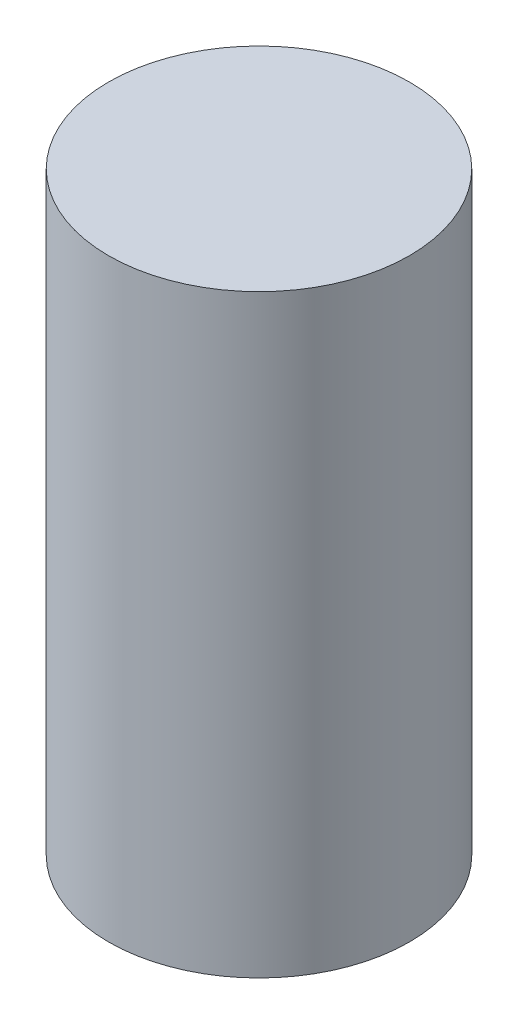
from build123d import *

# Parameters (mm, degrees)
SKETCH1_R           = 10.125
BOSS_EXTRUDE1_DEPTH = 10
SKETCH2_R           = 10.125
BOSS_EXTRUDE2_DEPTH = 30


with BuildPart() as part:
    # Sketch1 → Boss-Extrude1 (new body)
    with BuildSketch(Plane(origin=(0, 0, 0), x_dir=(1, 0, 0), z_dir=(0, 1, 0))):
        Circle(SKETCH1_R)
        with BuildLine():
            Line((9.3566828, 0.79375), (5.365749064, 7.70625))
            ThreePointArc((5.365749064, 7.70625), (4.784683736, 8.287315329), (3.990933736, 8.5))
            Line((3.990933736, 8.5), (-3.990933736, 8.5))
            ThreePointArc((-3.990933736, 8.5), (-4.784683736, 8.287315329), (-5.365749064, 7.70625))
            Line((-5.365749064, 7.70625), (-9.3566828, 0.79375))
            ThreePointArc((-9.3566828, 0.79375), (-9.569367472, 0), (-9.3566828, -0.79375))
            Line((-9.3566828, -0.79375), (-5.365749064, -7.70625))
            ThreePointArc((-5.365749064, -7.70625), (-4.784683736, -8.287315329), (-3.990933736, -8.5))
            Line((-3.990933736, -8.5), (3.990933736, -8.5))
            ThreePointArc((3.990933736, -8.5), (4.784683736, -8.287315329), (5.365749064, -7.70625))
            Line((5.365749064, -7.70625), (9.3566828, -0.79375))
            ThreePointArc((9.3566828, -0.79375), (9.569367472, 0), (9.3566828, 0.79375))
        make_face(mode=Mode.SUBTRACT)
    extrude(amount=BOSS_EXTRUDE1_DEPTH)

    # Sketch2 → Boss-Extrude2 (add)
    with BuildSketch(Plane(origin=(0, 10, 0), x_dir=(1, 0, 0), z_dir=(0, 1, 0))):
        Circle(SKETCH2_R)
    extrude(amount=BOSS_EXTRUDE2_DEPTH)


solid = part.part
